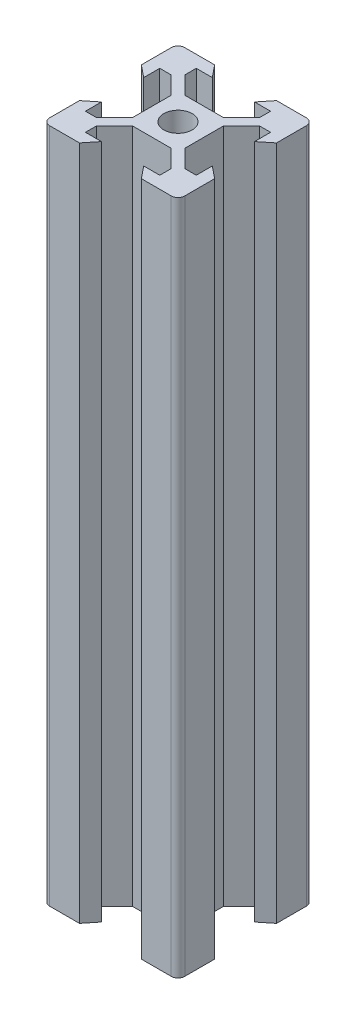
from build123d import *

# Parameters (mm, degrees)
SKETCH1_R           = 2.1
BOSS_EXTRUDE1_DEPTH = 100


with BuildPart() as part:
    # Sketch1 → Boss-Extrude1 (new body)
    with BuildSketch(Plane(origin=(0, 0, 0), x_dir=(1, 0, 0), z_dir=(0, 1, 0))):
        with BuildLine():
            Line((-5.5, 8.2), (-3.125, 8.2))
            Line((-3.125, 8.2), (-4.58, 10))
            Line((-4.58, 10), (-9, 10))
            ThreePointArc((-9, 10), (-9.707106781, 9.707106781), (-10, 9))
            Line((-10, 9), (-10, 4.58))
            Line((-10, 4.58), (-8.2, 3.125))
            Line((-8.2, 3.125), (-8.2, 5.5))
            Line((-8.2, 5.5), (-6.56, 5.5))
            Line((-6.56, 5.5), (-3.9, 2.84))
            Line((-3.9, 2.84), (-3.9, -2.84))
            Line((-3.9, -2.84), (-6.56, -5.5))
            Line((-6.56, -5.5), (-8.2, -5.5))
            Line((-8.2, -5.5), (-8.2, -3.125))
            Line((-8.2, -3.125), (-10, -4.58))
            Line((-10, -4.58), (-10, -9))
            ThreePointArc((-10, -9), (-9.707106781, -9.707106781), (-9, -10))
            Line((-9, -10), (-4.58, -10))
            Line((-4.58, -10), (-3.125, -8.2))
            Line((-3.125, -8.2), (-5.5, -8.2))
            Line((-5.5, -8.2), (-5.5, -6.56))
            Line((-5.5, -6.56), (-2.84, -3.9))
            Line((-2.84, -3.9), (2.84, -3.9))
            Line((2.84, -3.9), (5.5, -6.56))
            Line((5.5, -6.56), (5.5, -8.2))
            Line((5.5, -8.2), (3.125, -8.2))
            Line((3.125, -8.2), (4.58, -10))
            Line((4.58, -10), (9, -10))
            ThreePointArc((9, -10), (9.707106781, -9.707106781), (10, -9))
            Line((10, -9), (10, -4.58))
            Line((10, -4.58), (8.2, -3.125))
            Line((8.2, -3.125), (8.2, -5.5))
            Line((8.2, -5.5), (6.56, -5.5))
            Line((6.56, -5.5), (3.9, -2.84))
            Line((3.9, -2.84), (3.9, 2.84))
            Line((3.9, 2.84), (6.56, 5.5))
            Line((6.56, 5.5), (8.2, 5.5))
            Line((8.2, 5.5), (8.2, 3.125))
            Line((8.2, 3.125), (10, 4.58))
            Line((10, 4.58), (10, 9))
            ThreePointArc((10, 9), (9.707106781, 9.707106781), (9, 10))
            Line((9, 10), (4.58, 10))
            Line((4.58, 10), (3.125, 8.2))
            Line((3.125, 8.2), (5.5, 8.2))
            Line((5.5, 8.2), (5.5, 6.56))
            Line((5.5, 6.56), (2.84, 3.9))
            Line((2.84, 3.9), (-2.84, 3.9))
            Line((-2.84, 3.9), (-5.5, 6.56))
            Line((-5.5, 6.56), (-5.5, 8.2))
        make_face()
        Circle(SKETCH1_R, mode=Mode.SUBTRACT)
    extrude(amount=BOSS_EXTRUDE1_DEPTH)


solid = part.part
